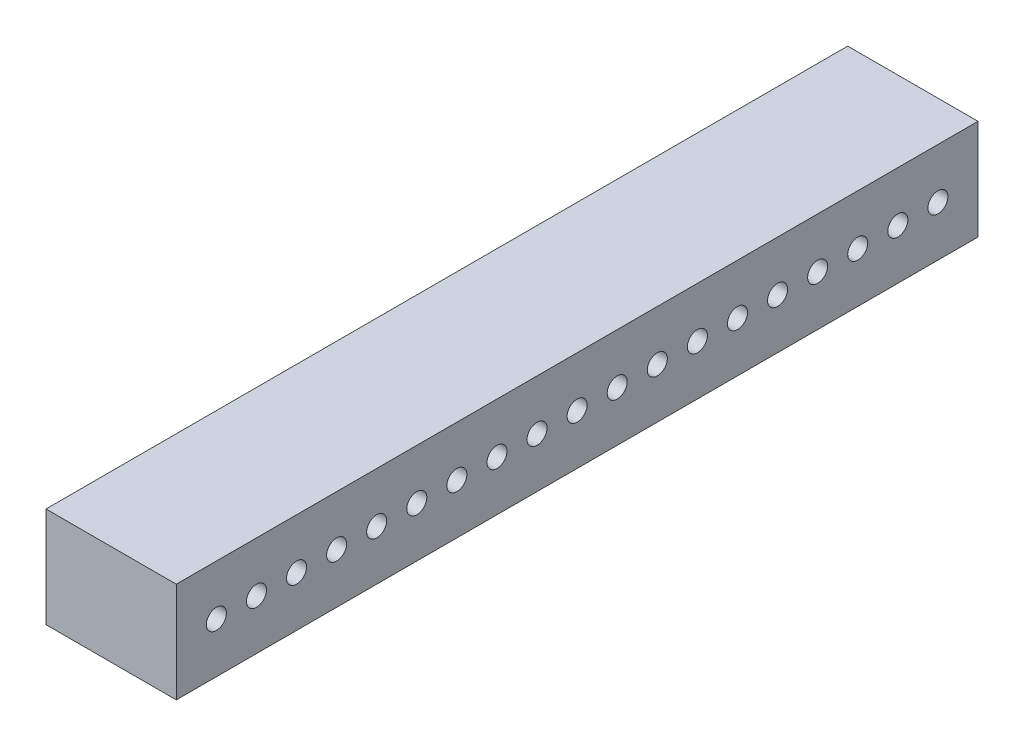
from build123d import *

# Parameters (mm, degrees)
SKETCH1_W           = 400
SKETCH1_H           = 50
BOSS_EXTRUDE1_DEPTH = 65
SKETCH2_R           = 5
CUT_EXTRUDE1_DEPTH  = 66


with BuildPart() as part:
    # Sketch1 → Boss-Extrude1 (new body)
    with BuildSketch(Plane(origin=(0, 0, 0), x_dir=(0, 0, -1), z_dir=(1, 0, 0))):
        Rectangle(SKETCH1_W, SKETCH1_H)
    extrude(amount=BOSS_EXTRUDE1_DEPTH)

    # Sketch2 → Cut-Extrude1 (cut, through all)
    with BuildSketch(Plane(origin=(65, 0, 0), x_dir=(0, 0, -1), z_dir=(1, 0, 0))):
        with Locations((-180, 0)):
            Circle(SKETCH2_R)
        with Locations((-160, 0)):
            Circle(SKETCH2_R)
        with Locations((-140, 0)):
            Circle(SKETCH2_R)
        with Locations((-120, 0)):
            Circle(SKETCH2_R)
        with Locations((-100, 0)):
            Circle(SKETCH2_R)
        with Locations((-80, 0)):
            Circle(SKETCH2_R)
        with Locations((-60, 0)):
            Circle(SKETCH2_R)
        with Locations((-40, 0)):
            Circle(SKETCH2_R)
        with Locations((-20, 0)):
            Circle(SKETCH2_R)
        Circle(SKETCH2_R)
        with Locations((20, 0)):
            Circle(SKETCH2_R)
        with Locations((40, 0)):
            Circle(SKETCH2_R)
        with Locations((60, 0)):
            Circle(SKETCH2_R)
        with Locations((80, 0)):
            Circle(SKETCH2_R)
        with Locations((100, 0)):
            Circle(SKETCH2_R)
        with Locations((120, 0)):
            Circle(SKETCH2_R)
        with Locations((140, 0)):
            Circle(SKETCH2_R)
        with Locations((160, 0)):
            Circle(SKETCH2_R)
        with Locations((180, 0)):
            Circle(SKETCH2_R)
    extrude(amount=-CUT_EXTRUDE1_DEPTH, mode=Mode.SUBTRACT)


solid = part.part
